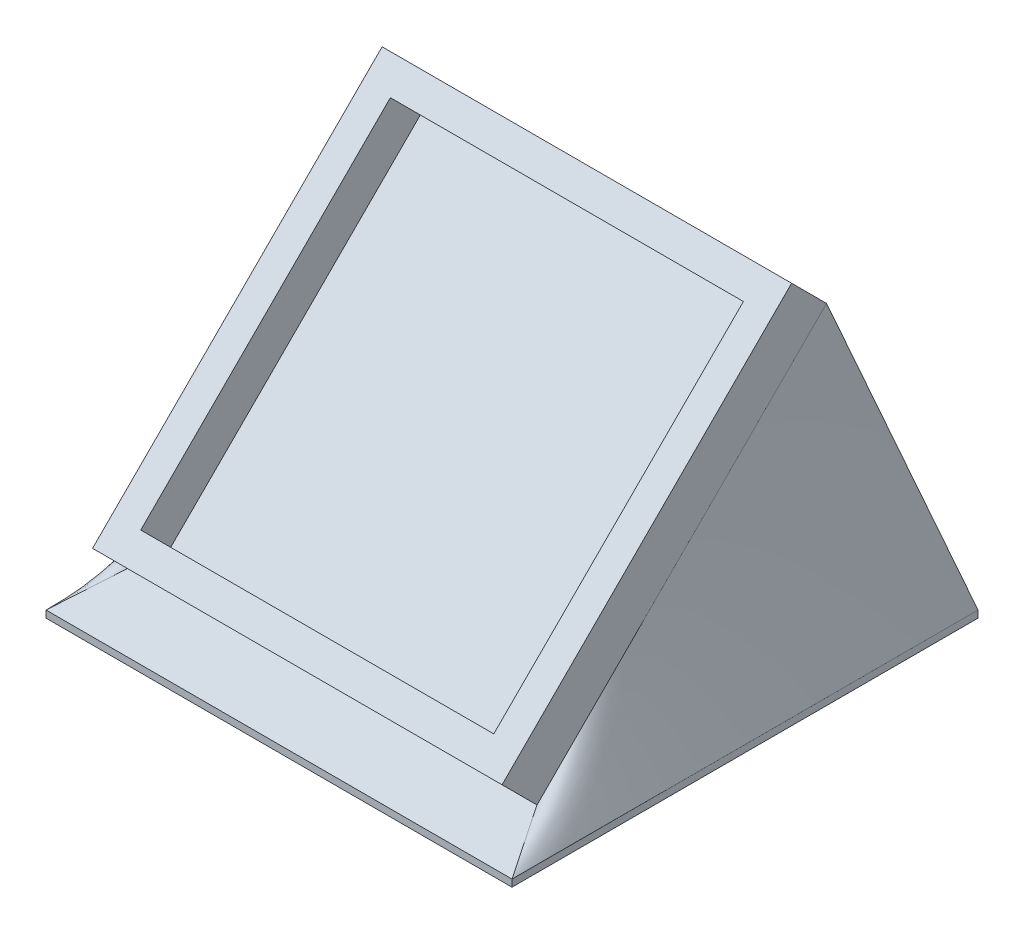
from build123d import *

# Parameters (mm, degrees)
SKETCH1_W             = 36.83
SKETCH1_H             = 36.83
BOSS_EXTRUDE1_DEPTH   = 0.635
SKETCH2_W             = 36.83
SKETCH2_H             = 36.83
SKETCH2_W_2           = 31.75
SKETCH2_H_2           = 31.75
BOSS_EXTRUDE2_DEPTH   = 3.81
SKETCH3_W             = 41.91
SKETCH3_H             = 41.91
BOSS_EXTRUDE3_DEPTH   = 0.635
BODY_MOVE_COPY2_ANGLE = 45
CUT_EXTRUDE1_DEPTH    = 0.635


with BuildPart() as part:
    # Sketch1 → Boss-Extrude1 (new body)
    with BuildSketch(Plane(origin=(0, 0, 0), x_dir=(1, 0, 0), z_dir=(0, 1, 0))):
        with Locations((-3.873751075, -5.413720286)):
            Rectangle(SKETCH1_W, SKETCH1_H)
    extrude(amount=BOSS_EXTRUDE1_DEPTH)

    # Sketch2 → Boss-Extrude2 (add)
    with BuildSketch(Plane(origin=(0, 0.635, 0), x_dir=(1, 0, 0), z_dir=(0, 1, 0))):
        with Locations((-3.873751075, -5.413720286)):
            Rectangle(SKETCH2_W, SKETCH2_H)
        with Locations((-3.873751075, -5.413720286)):
            Rectangle(SKETCH2_W_2, SKETCH2_H_2, mode=Mode.SUBTRACT)
    extrude(amount=BOSS_EXTRUDE2_DEPTH)


with BuildPart() as part_1:
    # Body-Move/Copy1: moved
    add(part.part.moved(Location((0, 20.32, 0))))


with BuildPart() as body_2:
    # Sketch3 → Boss-Extrude3 (new body)
    with BuildSketch(Plane(origin=(0, 0, 0), x_dir=(1, 0, 0), z_dir=(0, 1, 0))):
        with Locations((-3.873751075, -5.413720286)):
            Rectangle(SKETCH3_W, SKETCH3_H)
    extrude(amount=BOSS_EXTRUDE3_DEPTH)


with BuildPart() as part_2:
    # Body-Move/Copy2: moved
    add(part_1.part.moved(Location((0, 0, 0))).rotate(Axis((0, 4.7625, 5.413720286), (1, 0, 0)), BODY_MOVE_COPY2_ANGLE))


with BuildPart() as part_3:
    # Body-Move/Copy3: moved
    add(part_2.part.moved(Location((0, 0, -7.855385397))))


    add(body_2.part)  # loft1 joins it to this body
    # loft from a face of the part (loft1)
    loft([part_3.faces().sort_by_distance((-3.873751075, 15.763313748, 8.559148637))[0], part_3.faces().sort_by_distance((-3.873751075, 0.635, 5.413720286))[0]])

    # Sketch4 → Cut-Extrude1 (cut)
    with BuildSketch(Plane(origin=(0, 16.623453931, -16.623453931), x_dir=(1, 0, 0), z_dir=(0, 0.7071067811865487, -0.7071067811865464))):
        Polygon((12.496076649, -20.788321678), (12.432274566, -20.788321678), (12.432274566, -18.365244754), (12.028428412, -18.365244754), (12.028428412, -18.006270396), (12.432274566, -18.006270396), (12.432274566, -17.198578088), (12.74637713, -17.198578088), (12.74637713, -18.006270396), (14.40663354, -18.006270396), align=None)
        Polygon((12.74637713, -18.365244754), (12.74637713, -19.885276806), (13.789646361, -18.365244754), align=None, mode=Mode.SUBTRACT)
        with BuildLine():
            Line((9.515607899, -20.698578088), (9.515607899, -20.339603729))
            Line((9.515607899, -20.339603729), (10.706112707, -20.339603729))
            Line((10.706112707, -20.339603729), (10.89471447, -19.419030812))
            add(Edge.make_bspline(
                [(10.89471447, -19.419030812), (10.857658595, -19.429261084), (10.7858687, -19.449080618), (10.679908839, -19.471086388), (10.579316635, -19.484351832), (10.514041265, -19.486163143), (10.482454854, -19.487039626)],
                knots=[0, 0, 0, 0, 1.100273476, 2.13160584, 3.095893838, 4, 4, 4, 4], degree=3))
            add(Edge.make_bspline(
                [(10.482454854, -19.487039626), (10.443364075, -19.486221406), (10.366501837, -19.48461258), (10.254215614, -19.468254567), (10.14649524, -19.444545316), (10.044890128, -19.408075965), (9.947762196, -19.363253356), (9.856428257, -19.307531045), (9.770459285, -19.241703046), (9.690043192, -19.167119738), (9.617545261, -19.084079396), (9.554294709, -18.99472057), (9.500230654, -18.900040372), (9.45710355, -18.799167906), (9.422136899, -18.693053786), (9.399016909, -18.5808076), (9.383591349, -18.463363242), (9.381870193, -18.383058149), (9.380992515, -18.342107735)],
                knots=[0, 0, 0, 0, 1.052656913, 2.069786496, 3.052102726, 4.020122636, 4.972424848, 5.930457368, 6.896570172, 7.885826804, 8.881139003, 9.861434336, 10.831623367, 11.813212553, 12.812997731, 13.836986694, 14.897002833, 16, 16, 16, 16], degree=3))
            add(Edge.make_bspline(
                [(9.380992515, -18.342107735), (9.381658099, -18.313585656), (9.382980274, -18.256926948), (9.389691392, -18.172780683), (9.402654897, -18.090425529), (9.419872999, -18.01002461), (9.442768219, -17.931457941), (9.469842953, -17.854540151), (9.502249583, -17.77939849), (9.539229984, -17.706406857), (9.581303981, -17.637001912), (9.626206391, -17.570374939), (9.675134434, -17.508458855), (9.72723159, -17.450218721), (9.783498175, -17.397329626), (9.842553402, -17.347585279), (9.905717864, -17.303095668), (9.971878022, -17.262177992), (10.040987464, -17.225541174), (10.113748217, -17.194979709), (10.188562648, -17.168192268), (10.266097666, -17.146408593), (10.346203034, -17.129507606), (10.42915461, -17.117998264), (10.514536155, -17.109624216), (10.572411048, -17.109099533), (10.60164556, -17.108834498)],
                knots=[0, 0, 0, 0, 1.056281413, 2.098288097, 3.122646807, 4.141030392, 5.140675379, 6.150604744, 7.15845591, 8.168533554, 9.177684096, 10.161739049, 11.141561652, 12.097360316, 13.052218386, 13.998410789, 14.954052752, 15.909851415, 16.877523809, 17.846742625, 18.829312613, 19.818263486, 20.826374662, 21.858017533, 22.918014209, 24, 24, 24, 24], degree=3))
            add(Edge.make_bspline(
                [(10.60164556, -17.108834498), (10.636518808, -17.109527255), (10.705127803, -17.110890172), (10.805661666, -17.125081305), (10.902327719, -17.145545108), (10.994725044, -17.175847071), (11.082419123, -17.215583214), (11.166682045, -17.262492061), (11.245971381, -17.319109182), (11.320849648, -17.383404876), (11.38953782, -17.454716863), (11.452773021, -17.530532234), (11.507526782, -17.612532549), (11.555102401, -17.699349781), (11.595573873, -17.791210263), (11.627396184, -17.888327209), (11.653072533, -17.990228872), (11.66393623, -18.060382154), (11.669454053, -18.096013985)],
                knots=[0, 0, 0, 0, 1.04695683, 2.059763882, 3.044413726, 4.012427942, 4.974081556, 5.932886124, 6.904940154, 7.895678616, 8.893654631, 9.876199664, 10.857615262, 11.850515636, 12.847107701, 13.868396357, 14.917328757, 16, 16, 16, 16], degree=3))
            Line((11.669454053, -18.096013985), (11.355351489, -18.096013985))
            add(Edge.make_bspline(
                [(11.355351489, -18.096013985), (11.347632635, -18.062630834), (11.332796569, -17.998466565), (11.30006169, -17.908424364), (11.260670817, -17.827852194), (11.211659131, -17.757256751), (11.155987105, -17.694261786), (11.091732575, -17.638242063), (11.019441571, -17.588311986), (10.939097948, -17.546352734), (10.854119248, -17.511059933), (10.765698985, -17.485861254), (10.675092692, -17.470610914), (10.614090172, -17.468746391), (10.583416393, -17.467808857)],
                knots=[0, 0, 0, 0, 1.136370375, 2.184166959, 3.172867797, 4.104539607, 5.027679118, 5.956634301, 6.927059835, 7.936867459, 8.959641981, 9.976160943, 10.98235693, 12, 12, 12, 12], degree=3))
            add(Edge.make_bspline(
                [(10.583416393, -17.467808857), (10.55346049, -17.468636502), (10.494477072, -17.470266143), (10.407629233, -17.482606652), (10.324025979, -17.50211168), (10.243518903, -17.529437107), (10.166503601, -17.565587046), (10.093088965, -17.609995162), (10.022229138, -17.661553513), (9.955789045, -17.720482826), (9.894952803, -17.785459847), (9.841195844, -17.854935326), (9.79641915, -17.929052674), (9.758684983, -18.006525694), (9.7300317, -18.088204287), (9.709590714, -18.173705452), (9.697587657, -18.263240435), (9.695936476, -18.324309744), (9.695095079, -18.355429049)],
                knots=[0, 0, 0, 0, 1.027268864, 2.022700798, 3.002744649, 3.968653148, 4.933396556, 5.915045722, 6.907600446, 7.935526002, 8.956456544, 9.95700807, 10.942805781, 11.92166854, 12.907987664, 13.905483474, 14.932689774, 16, 16, 16, 16], degree=3))
            add(Edge.make_bspline(
                [(9.695095079, -18.355429049), (9.695626903, -18.383525147), (9.696664084, -18.438319137), (9.708930088, -18.518410136), (9.725451429, -18.594861409), (9.75150856, -18.666958643), (9.783158628, -18.735454531), (9.824397356, -18.79865662), (9.869989448, -18.85965524), (9.92458909, -18.914417666), (9.983707922, -18.965383202), (10.049222261, -19.008609143), (10.119259841, -19.04538637), (10.193983885, -19.075514305), (10.27347734, -19.099514733), (10.357785544, -19.116101446), (10.446927005, -19.126026763), (10.507902654, -19.127373176), (10.53924572, -19.128065267)],
                knots=[0, 0, 0, 0, 1.045820996, 2.039596555, 3.013371638, 3.9552447, 4.890047302, 5.817684688, 6.761648481, 7.722253242, 8.692244539, 9.66551337, 10.63924952, 11.635311376, 12.662847378, 13.728455105, 14.832366986, 16, 16, 16, 16], degree=3))
            add(Edge.make_bspline(
                [(10.53924572, -19.128065267), (10.566610243, -19.127504392), (10.622629669, -19.126356192), (10.708759442, -19.117320099), (10.798875042, -19.103418938), (10.893326327, -19.08338293), (10.991854092, -19.058296469), (11.094622189, -19.026966624), (11.201633102, -18.990878593), (11.273659109, -18.962887487), (11.310479694, -18.948578088)],
                knots=[0, 0, 0, 0, 0.824638674, 1.688163388, 2.607705698, 3.571998603, 4.597075385, 5.671199175, 6.809488238, 8, 8, 8, 8], degree=3))
            Line((11.310479694, -18.948578088), (10.951505335, -20.698578088))
            Line((10.951505335, -20.698578088), (9.515607899, -20.698578088))
        make_face()
        Polygon((7.67586431, -19.756270396), (7.302166393, -19.756270396), (6.643813027, -18.833594113), (5.985459662, -19.756270396), (5.611761745, -19.756270396), (6.456613508, -18.572075684), (5.477146361, -17.198578088), (5.850844277, -17.198578088), (6.643813027, -18.309856133), (7.436781777, -17.198578088), (7.810479694, -17.198578088), (6.830311425, -18.572075684), align=None)
        with BuildLine():
            add(Edge.make_bspline(
                [(3.99637713, -18.947175844), (3.996049112, -19.003273232), (3.995411932, -19.112243216), (3.988323511, -19.271027858), (3.976548169, -19.419988148), (3.960410793, -19.559131211), (3.940772824, -19.688492986), (3.914557301, -19.807727708), (3.88474462, -19.917387431), (3.850191764, -20.01782909), (3.811205388, -20.110408133), (3.768766144, -20.196828611), (3.721219021, -20.27698729), (3.671178934, -20.352065211), (3.616894574, -20.421306811), (3.558554715, -20.484400907), (3.496673219, -20.542325236), (3.43095728, -20.594127305), (3.362033253, -20.639265898), (3.291940001, -20.680183012), (3.21867832, -20.712549578), (3.14405525, -20.74022672), (3.06746957, -20.762150757), (2.988887917, -20.777400645), (2.908239774, -20.786941299), (2.853809265, -20.787857186), (2.826204854, -20.788321678)],
                knots=[0, 0, 0, 0, 1.64625301, 3.197870201, 4.6634513, 6.030635694, 7.308242971, 8.501545196, 9.611429483, 10.641742253, 11.616230371, 12.55791849, 13.464870342, 14.34944951, 15.20427819, 16.044004467, 16.869007726, 17.689551165, 18.496129964, 19.285613293, 20.0683943, 20.843080271, 21.620342827, 22.403213977, 23.190190624, 24, 24, 24, 24], degree=3))
            add(Edge.make_bspline(
                [(2.826204854, -20.788321678), (2.798355877, -20.787935428), (2.742946213, -20.787166926), (2.661321064, -20.776349808), (2.581117687, -20.762387839), (2.503552924, -20.739995141), (2.427160175, -20.713199374), (2.353839174, -20.677842785), (2.281001303, -20.639389749), (2.211955487, -20.59248028), (2.144638766, -20.540637596), (2.081536367, -20.481782897), (2.021035227, -20.417544992), (1.965420448, -20.346491188), (1.912308459, -20.269710951), (1.863715444, -20.186560641), (1.818630758, -20.097224531), (1.776206928, -20.002116769), (1.739108409, -19.898696881), (1.70612486, -19.787609922), (1.679089261, -19.667849948), (1.656731296, -19.540084096), (1.639377259, -19.403679418), (1.626747284, -19.258912284), (1.62007344, -19.105692126), (1.618816846, -19.000934244), (1.618172002, -18.947175844)],
                knots=[0, 0, 0, 0, 0.810910589, 1.61342667, 2.396193133, 3.181089899, 3.963115317, 4.752255436, 5.550715454, 6.36105385, 7.181178335, 8.024612154, 8.872680183, 9.750181803, 10.651284446, 11.591556747, 12.554036451, 13.566402641, 14.62422919, 15.753422176, 16.94128843, 18.199818041, 19.531985927, 20.947085226, 22.433341622, 24, 24, 24, 24], degree=3))
            add(Edge.make_bspline(
                [(1.618172002, -18.947175844), (1.618831836, -18.893652604), (1.620120373, -18.78913131), (1.626595397, -18.636590623), (1.639715827, -18.492613447), (1.655707259, -18.356991185), (1.678763775, -18.229901118), (1.704432567, -18.110660725), (1.737174552, -18.000390412), (1.773393102, -17.897857014), (1.815226633, -17.803152138), (1.859971778, -17.714184778), (1.909290175, -17.631506364), (1.961383043, -17.554239455), (2.01805072, -17.483795026), (2.0777331, -17.418838543), (2.14144769, -17.359881591), (2.20911094, -17.307426785), (2.278809363, -17.260163951), (2.351661434, -17.220339796), (2.425961755, -17.18562126), (2.502483143, -17.157711617), (2.580737646, -17.135648935), (2.66100707, -17.120629878), (2.742957129, -17.110043334), (2.798359528, -17.109238838), (2.826204854, -17.108834498)],
                knots=[0, 0, 0, 0, 1.561431216, 3.049195289, 4.452146966, 5.778046447, 7.031138842, 8.218704273, 9.334037798, 10.384210803, 11.388620812, 12.352076869, 13.287433199, 14.19507451, 15.06813243, 15.922055533, 16.766344942, 17.596869952, 18.417486629, 19.220035357, 20.016159057, 20.807716045, 21.59340902, 22.384936649, 23.188266813, 24, 24, 24, 24], degree=3))
            add(Edge.make_bspline(
                [(2.826204854, -17.108834498), (2.853808303, -17.109303106), (2.908236915, -17.11022711), (2.988898954, -17.119708304), (3.067366668, -17.135168938), (3.143796925, -17.156164399), (3.218346121, -17.182848395), (3.290284046, -17.21678941), (3.36056048, -17.256155857), (3.428855782, -17.300941989), (3.49386435, -17.352267906), (3.555973711, -17.409024615), (3.613558195, -17.472674801), (3.66746819, -17.542202555), (3.717923473, -17.617469471), (3.765269248, -17.698241809), (3.80757925, -17.78550417), (3.847449596, -17.878585784), (3.88259561, -17.979765463), (3.913284461, -18.089800973), (3.939157955, -18.209442859), (3.959766553, -18.338696847), (3.976649592, -18.477362845), (3.988311902, -18.625661823), (3.995408388, -18.783276138), (3.996048323, -18.891545646), (3.99637713, -18.947175844)],
                knots=[0, 0, 0, 0, 0.810976328, 1.599087026, 2.383086309, 3.159618043, 3.926613167, 4.707144544, 5.494386734, 6.292609454, 7.104690378, 7.92621526, 8.762510248, 9.62398222, 10.509836085, 11.424023232, 12.373226806, 13.358118208, 14.398657954, 15.5185989, 16.713620699, 17.994156382, 19.364120462, 20.818119981, 22.365111093, 24, 24, 24, 24], degree=3))
        make_face()
        with BuildLine():
            add(Edge.make_bspline(
                [(3.682274566, -18.948578088), (3.6821525, -18.901829576), (3.681915593, -18.811099894), (3.675905685, -18.67948707), (3.667540508, -18.556525536), (3.657016629, -18.442263288), (3.641255638, -18.337099653), (3.623373788, -18.240597475), (3.60192574, -18.152935224), (3.57642326, -18.073347348), (3.547374987, -18.000705119), (3.515709793, -17.933078363), (3.481409545, -17.8696445), (3.443687292, -17.8106324), (3.402002582, -17.756371659), (3.357285834, -17.706604575), (3.309277031, -17.661533786), (3.242832945, -17.608043892), (3.155541084, -17.552118283), (3.044994671, -17.504016943), (2.931353179, -17.473592932), (2.85419838, -17.469734647), (2.815688027, -17.467808857)],
                knots=[0, 0, 0, 0, 1.459193451, 2.832007961, 4.111736495, 5.306635028, 6.412683014, 7.430020708, 8.369596877, 9.227877302, 10.036669781, 10.810175692, 11.557788084, 12.286326232, 12.994037279, 13.69140682, 14.37267704, 15.047194847, 16.352618509, 17.594157723, 18.799169539, 20, 20, 20, 20], degree=3))
            add(Edge.make_bspline(
                [(2.815688027, -17.467808857), (2.776956543, -17.469497511), (2.699630962, -17.472868829), (2.586066821, -17.502292362), (2.476730334, -17.550125684), (2.390443138, -17.60477412), (2.324979539, -17.657150813), (2.278058644, -17.701755493), (2.234997681, -17.751714131), (2.194155305, -17.805612657), (2.156696313, -17.864485356), (2.122633152, -17.92804787), (2.091549811, -17.996477065), (2.073840764, -18.044246802), (2.064786585, -18.068670235)],
                knots=[0, 0, 0, 0, 1.353621445, 2.702441307, 4.075953605, 5.516772412, 6.261413105, 7.007624062, 7.778524365, 8.566925914, 9.372323995, 10.217594641, 11.088702136, 12, 12, 12, 12], degree=3))
            add(Edge.make_bspline(
                [(2.064786585, -18.068670235), (2.054234817, -18.099899975), (2.032810204, -18.163309739), (2.005198429, -18.261673391), (1.98345303, -18.364876155), (1.963889664, -18.472301272), (1.950536608, -18.584740973), (1.939788795, -18.701847357), (1.933458108, -18.823708719), (1.932673357, -18.90650371), (1.932274566, -18.948578088)],
                knots=[0, 0, 0, 0, 0.884706709, 1.796334032, 2.740027952, 3.714592787, 4.726048262, 5.777819803, 6.87074269, 8, 8, 8, 8], degree=3))
            add(Edge.make_bspline(
                [(1.932274566, -18.948578088), (1.93271439, -18.990651561), (1.933574886, -19.072966451), (1.939228424, -19.193393208), (1.94831319, -19.30797255), (1.960609222, -19.416808419), (1.977489071, -19.519707102), (1.997760099, -19.616815833), (2.021525518, -19.70810848), (2.048785288, -19.793820315), (2.079506233, -19.873643832), (2.113445177, -19.947750864), (2.149657403, -20.016541106), (2.189015023, -20.079793298), (2.230961194, -20.13787652), (2.277002054, -20.189453732), (2.324213125, -20.237034023), (2.391357259, -20.290375033), (2.478545947, -20.34519173), (2.587786506, -20.394265118), (2.700845774, -20.423308074), (2.777434878, -20.427335689), (2.815688027, -20.429347319)],
                knots=[0, 0, 0, 0, 1.313528337, 2.569860077, 3.762944266, 4.901481389, 5.988248151, 7.017139294, 7.997571128, 8.932104357, 9.823695246, 10.66607014, 11.475539426, 12.248954257, 12.990316782, 13.708962568, 14.405488541, 15.08007697, 16.381737273, 17.610043218, 18.806313575, 20, 20, 20, 20], degree=3))
            add(Edge.make_bspline(
                [(2.815688027, -20.429347319), (2.854406128, -20.427333308), (2.931912863, -20.423301618), (3.04615486, -20.394367587), (3.156049382, -20.345540755), (3.243054335, -20.290307248), (3.309253216, -20.237241176), (3.356361521, -20.191950406), (3.400819468, -20.142648748), (3.442304485, -20.088634027), (3.479796583, -20.029734452), (3.51451372, -19.966760447), (3.54592628, -19.899234148), (3.575084198, -19.826632069), (3.600316083, -19.746913416), (3.623002489, -19.659268647), (3.640512981, -19.562138873), (3.656060759, -19.45648139), (3.667813112, -19.342083291), (3.675847385, -19.218830679), (3.681933847, -19.086759061), (3.682158718, -18.995560938), (3.682274566, -18.948578088)],
                knots=[0, 0, 0, 0, 1.207779899, 2.417760083, 3.652287919, 4.947299644, 5.621638849, 6.297435916, 6.984320042, 7.691843698, 8.42018894, 9.161205785, 9.934506883, 10.743085206, 11.601138371, 12.542248028, 13.566483018, 14.679455109, 15.87477181, 17.154161492, 18.533899613, 20, 20, 20, 20], degree=3))
        make_face(mode=Mode.SUBTRACT)
    extrude(amount=-CUT_EXTRUDE1_DEPTH, mode=Mode.SUBTRACT)


solid = part_3.part
